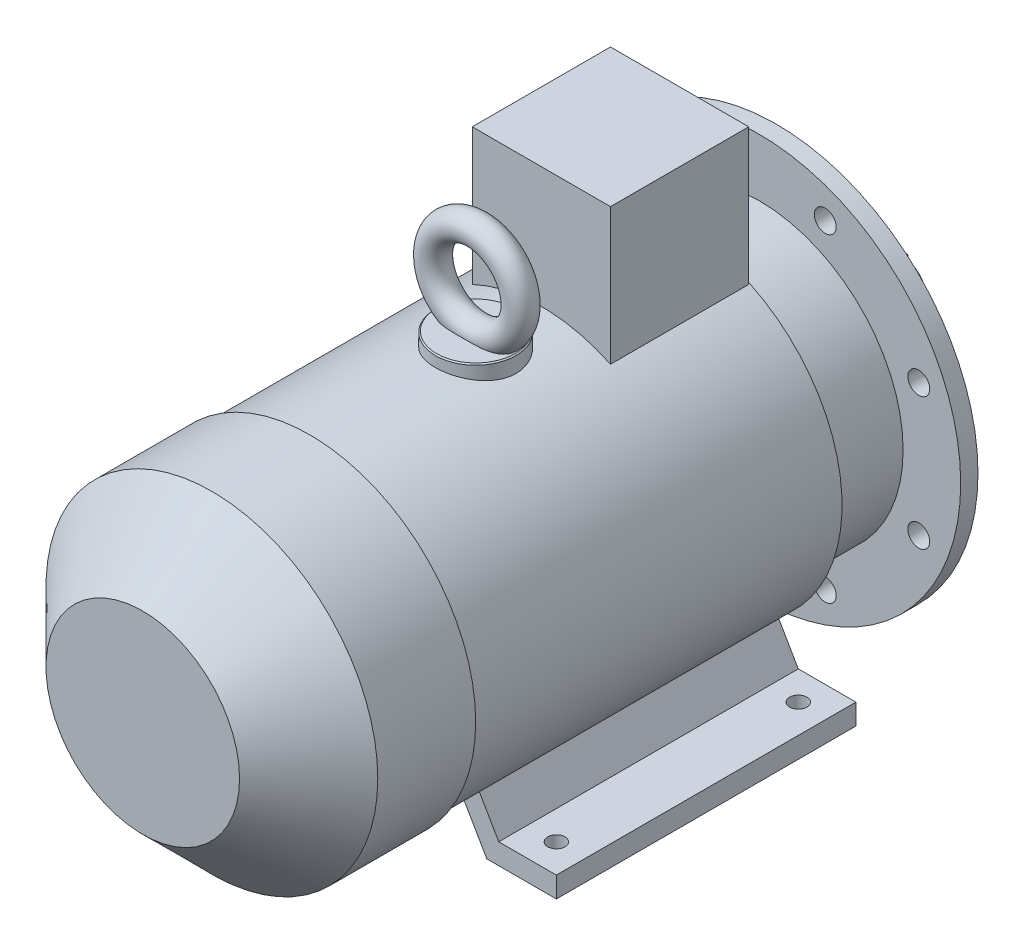
from build123d import *

# Parameters (mm, degrees)
SKETCH_1_R           = 21
EXTRUDE_1_DEPTH      = 110
SKETCH_2_W           = 8
SKETCH_2_H           = 8
EXTRUDE_2_DEPTH      = 0.1
EXTRUDE_2_DEPTH_BACK = 55
SKETCH_3_R           = 175
EXTRUDE_3_DEPTH      = 15
SKETCH_4_R           = 125
SKETCH_4_R_2         = 116
EXTRUDE_4_DEPTH      = 5
SKETCH_5_R           = 116
SKETCH_5_R_2         = 40
CUT_EXTRUDE_1_DEPTH  = 8
CHAMFER_1_SIZE       = 1
SKETCH_6_R           = 9.5
CUT_EXTRUDE_2_DEPTH  = 16
SKETCH_7_R           = 125
EXTRUDE_5_DEPTH      = 68
SKETCH_8_R           = 140
EXTRUDE_6_DEPTH      = 322
SKETCH_9_R           = 144
EXTRUDE_7_DEPTH      = 145
CHAMFER_2_SIZE       = 60
EXTRUDE_8_DEPTH      = 260
CUT_EXTRUDE_3_REACH  = 337
SKETCH_11_R          = 7.5
SKETCH_12_W          = 120
SKETCH_12_H          = 120
EXTRUDE_9_DEPTH      = 245
SKETCH_13_R          = 35
EXTRUDE_10_DEPTH     = 150
CHAMFER_3_SIZE       = 1
SKETCH_15_R          = 12
SKETCH_16_R          = 16
EXTRUDE_11_DEPTH     = 14
EXTRUDE_12_DEPTH     = 16
SKETCH_18_R          = 7
CUT_EXTRUDE_4_DEPTH  = 16


with BuildPart() as part:
    # Эскиз1 → Вытянуть1 (new body)
    with BuildSketch(Plane.XY):
        Circle(SKETCH_1_R)
    extrude(amount=EXTRUDE_1_DEPTH)

    # Эскиз2 → Вытянуть2 (add, two sides)
    with BuildSketch(Plane(origin=(0, 0, 0), x_dir=(-1, 0, 0), z_dir=(0, 0, -1))) as extrude_2_sk:
        with Locations((0, 20)):
            Rectangle(SKETCH_2_W, SKETCH_2_H)
    extrude(amount=EXTRUDE_2_DEPTH)
    extrude(extrude_2_sk.sketch, amount=-EXTRUDE_2_DEPTH_BACK)

    # Эскиз3 → Вытянуть3 (add)
    with BuildSketch(Plane.XY.offset(110)):
        Circle(SKETCH_3_R)
    extrude(amount=EXTRUDE_3_DEPTH)

    # Эскиз4 → Вытянуть4 (add)
    with BuildSketch(Plane(origin=(0, 0, 110), x_dir=(-1, 0, 0), z_dir=(0, 0, -1))):
        with Locations(Location((0, 0, 0), (0, 0, 180))):  # turned: the seam where the file's is
            Circle(SKETCH_4_R)
        Circle(SKETCH_4_R_2, mode=Mode.SUBTRACT)
    extrude(amount=EXTRUDE_4_DEPTH)

    # Эскиз5 → Вырез-Вытянуть1 (cut)
    with BuildSketch(Plane(origin=(0, 0, 110), x_dir=(-1, 0, 0), z_dir=(0, 0, -1))):
        Circle(SKETCH_5_R)
        Circle(SKETCH_5_R_2, mode=Mode.SUBTRACT)
    extrude(amount=-CUT_EXTRUDE_1_DEPTH, mode=Mode.SUBTRACT)

    # Фаска1
    chamfer_1_edges = [part.edges().sort_by_distance(p)[0] for p in [
        (-125, 0, 105),
        (40, 0, 110),
        (-13.360389216, -16.201851746, 0),
    ]]
    chamfer(chamfer_1_edges, length=CHAMFER_1_SIZE)

    # Эскиз6 → Вырез-Вытянуть2 (cut, through all)
    with BuildSketch(Plane(origin=(0, 0, 110), x_dir=(-1, 0, 0), z_dir=(0, 0, -1))):
        with Locations((-57.402514855, 138.581929877)):
            Circle(SKETCH_6_R)
        with Locations((57.402514855, 138.581929877)):
            Circle(SKETCH_6_R)
        with Locations((138.581929877, 57.402514855)):
            Circle(SKETCH_6_R)
        with Locations((138.581929877, -57.402514855)):
            Circle(SKETCH_6_R)
        with Locations((57.402514855, -138.581929877)):
            Circle(SKETCH_6_R)
        with Locations((-57.402514855, -138.581929877)):
            Circle(SKETCH_6_R)
        with Locations((-138.581929877, -57.402514855)):
            Circle(SKETCH_6_R)
        with Locations((-138.581929877, 57.402514855)):
            Circle(SKETCH_6_R)
    extrude(amount=-CUT_EXTRUDE_2_DEPTH, mode=Mode.SUBTRACT)

    # Эскиз7 → Вытянуть5 (add)
    with BuildSketch(Plane.XY.offset(125)):
        Circle(SKETCH_7_R)
    extrude(amount=EXTRUDE_5_DEPTH)

    # Эскиз8 → Вытянуть6 (add)
    with BuildSketch(Plane.XY.offset(193)):
        Circle(SKETCH_8_R)
    extrude(amount=EXTRUDE_6_DEPTH)

    # Эскиз9 → Вытянуть7 (add)
    with BuildSketch(Plane.XY.offset(515)):
        Circle(SKETCH_9_R)
    extrude(amount=EXTRUDE_7_DEPTH)

    # Фаска2
    chamfer_2_edges = [part.edges().sort_by_distance(p)[0] for p in [
        (-144, 0, 660),
    ]]
    chamfer(chamfer_2_edges, length=CHAMFER_2_SIZE)

    # Эскиз10 → Вытянуть8 (add)
    with BuildSketch(Plane(origin=(0, 0, 193), x_dir=(-1, 0, 0), z_dir=(0, 0, -1))):
        Polygon((-152, -160), (-91.607695155, -160), (-51.945448858, -91.302974272), (-67.533906126, -82.302974272), (-102, -142), (-152, -142), align=None)
        Polygon((91.607695155, -160), (51.945448858, -91.302974272), (67.533906126, -82.302974272), (102, -142), (152, -142), (152, -160), align=None)
    extrude(amount=-EXTRUDE_8_DEPTH)

    # Эскиз11 → Вырез-Вытянуть3 (cut, up to next)
    with BuildSketch(Plane.XZ.offset(160), mode=Mode.PRIVATE) as cut_extrude_3_sk1:
        with Locations((-127, 218)):
            Circle(SKETCH_11_R)
    cut_extrude_3_tool1 = extrude(cut_extrude_3_sk1.sketch, amount=-CUT_EXTRUDE_3_REACH, mode=Mode.PRIVATE) & part.part
    add(cut_extrude_3_tool1.solids().sort_by_distance((-127, -160, 218))[0], mode=Mode.SUBTRACT)
    # Эскиз11 → Вырез-Вытянуть3 (cut, up to next)
    with BuildSketch(Plane.XZ.offset(160), mode=Mode.PRIVATE) as cut_extrude_3_sk2:
        with Locations((127, 218)):
            Circle(SKETCH_11_R)
    cut_extrude_3_tool2 = extrude(cut_extrude_3_sk2.sketch, amount=-CUT_EXTRUDE_3_REACH, mode=Mode.PRIVATE) & part.part
    add(cut_extrude_3_tool2.solids().sort_by_distance((127, -160, 218))[0], mode=Mode.SUBTRACT)
    # Эскиз11 → Вырез-Вытянуть3 (cut, up to next)
    with BuildSketch(Plane.XZ.offset(160), mode=Mode.PRIVATE) as cut_extrude_3_sk3:
        with Locations((-127, 428)):
            Circle(SKETCH_11_R)
    cut_extrude_3_tool3 = extrude(cut_extrude_3_sk3.sketch, amount=-CUT_EXTRUDE_3_REACH, mode=Mode.PRIVATE) & part.part
    add(cut_extrude_3_tool3.solids().sort_by_distance((-127, -160, 428))[0], mode=Mode.SUBTRACT)
    # Эскиз11 → Вырез-Вытянуть3 (cut, up to next)
    with BuildSketch(Plane.XZ.offset(160), mode=Mode.PRIVATE) as cut_extrude_3_sk4:
        with Locations((127, 428)):
            Circle(SKETCH_11_R)
    cut_extrude_3_tool4 = extrude(cut_extrude_3_sk4.sketch, amount=-CUT_EXTRUDE_3_REACH, mode=Mode.PRIVATE) & part.part
    add(cut_extrude_3_tool4.solids().sort_by_distance((127, -160, 428))[0], mode=Mode.SUBTRACT)

    # Эскиз12 → Вытянуть9 (add)
    with BuildSketch(Plane(origin=(0, 0, 0), x_dir=(1, 0, 0), z_dir=(0, 1, 0))):
        with Locations((0, -254)):
            Rectangle(SKETCH_12_W, SKETCH_12_H)
    extrude(amount=EXTRUDE_9_DEPTH)

    # Эскиз13 → Вытянуть10 (add)
    with BuildSketch(Plane(origin=(0, 0, 0), x_dir=(1, 0, 0), z_dir=(0, 1, 0))):
        with Locations(Location((0, -371, 0), (0, 0, 90))):  # turned: the seam where the file's is
            Circle(SKETCH_13_R)
    extrude(amount=EXTRUDE_10_DEPTH)

    # Фаска3
    chamfer_3_edges = [part.edges().sort_by_distance(p)[0] for p in [
        (0, 150, 406),
    ]]
    chamfer(chamfer_3_edges, length=CHAMFER_3_SIZE)

    # По траектории1: sweep along a path in Эскиз14
    with BuildLine(Plane.XY.offset(370)) as sweep_1_path:
        CenterArc((0, 188), 38, 0, 360)
    # Эскиз15 → По траектории1 (sweep)
    with BuildSketch(Plane(origin=(0, 0, 0), x_dir=(0, 0, -1), z_dir=(1, 0, 0))):
        with Locations((-370, 226)):
            Circle(SKETCH_15_R)
    sweep(path=sweep_1_path.line)

    # Эскиз16 → Вытянуть11 (add)
    with BuildSketch(Plane.ZY.offset(60)):
        with Locations(Location((254, 185, 0), (0, 0, 180))):  # turned: the seam where the file's is
            Circle(SKETCH_16_R)
    extrude(amount=EXTRUDE_11_DEPTH)

    # Эскиз17 → Вытянуть12 (add)
    with BuildSketch(Plane.ZY.offset(74)):
        Polygon((254, 207.516660498), (234.5, 196.258330249), (234.5, 173.741669751), (254, 162.483339502), (273.5, 173.741669751), (273.5, 196.258330249), align=None)
    extrude(amount=EXTRUDE_12_DEPTH)

    # Эскиз18 → Вырез-Вытянуть4 (cut)
    with BuildSketch(Plane.ZY.offset(90)):
        with Locations((254, 185)):
            Circle(SKETCH_18_R)
    extrude(amount=-CUT_EXTRUDE_4_DEPTH, mode=Mode.SUBTRACT)


solid = part.part
